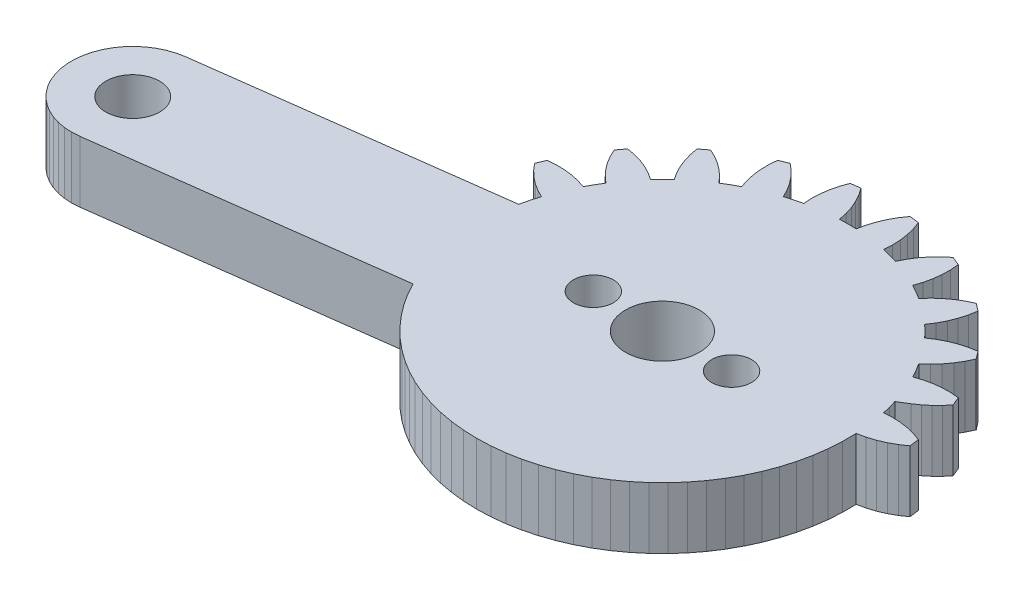
from build123d import *

# Parameters (mm, degrees)
SKETCH1_R           = 1.749998927
SKETCH1_R_2         = 1.299996615
SKETCH1_R_3         = 2.40000119
SKETCH1_R_4         = 1.299996531
BOSS_EXTRUDE1_DEPTH = 4.00000019


with BuildPart() as part:
    # Sketch1 → Boss-Extrude1 (new body)
    with BuildSketch(Plane.XZ):
        Polygon((36.249231547, 26.500970125), (35.366270691, 26.598049328), (34.478571266, 26.630060747), (33.590909094, 26.596819982), (32.708089799, 26.498520747), (31.834870577, 26.335669681), (30.975960195, 26.109160855), (30.135989189, 25.820219889), (29.319489375, 25.470390916), (28.530880809, 25.061579421), (27.774410322, 24.595979601), (27.054149657, 24.076100439), (26.373999193, 23.504760116), (25.737630203, 22.885030136), (25.148460642, 22.220259532), (24.609679356, 21.514030173), (24.124199525, 20.770160481), (23.694630712, 19.992660731), (4.522103816, 22.516779602), (4.020943772, 22.550940514), (3.519453108, 22.522019222), (3.025538987, 22.430479527), (2.54699192, 22.277759388), (2.091363072, 22.066259757), (1.665833988, 21.799329668), (1.277114963, 21.481169388), (0.931337476, 21.11678943), (0.633955002, 20.711960271), (0.389657886, 20.273039117), (0.202298193, 19.806969911), (0.074829914, 19.321080297), (0.009261072, 18.823059276), (0.006631017, 18.320739269), (0.06698072, 17.822049558), (0.189352795, 17.334859818), (0.371821196, 16.866849735), (0.611510186, 16.42539911), (0.90463832, 16.017470509), (1.246578991, 15.649499372), (1.631945022, 15.327280387), (2.05465802, 15.055909753), (2.508047968, 14.839650132), (2.984967083, 14.681920409), (3.477894003, 14.585220255), (22.650420666, 12.061100453), (22.789679468, 11.469890364), (22.958470508, 10.886400007), (22.47623913, 10.642839596), (22.020770237, 10.352309793), (21.596610546, 10.017720051), (21.207999438, 9.642422199), (20.858839154, 9.230175056), (21.09769918, 8.653513156), (21.636100486, 8.608905599), (22.176260129, 8.618320338), (22.712780163, 8.681657724), (23.240279406, 8.798288181), (23.753490299, 8.967043832), (24.014299735, 8.490939625), (24.296209216, 8.027019911), (23.893460631, 7.666944992), (23.528700694, 7.268427871), (23.205589503, 6.835460197), (22.927360609, 6.372373085), (22.696789354, 5.883802194), (23.076770827, 5.388610996), (23.60836044, 5.484871101), (24.127680808, 5.633769091), (24.629529566, 5.833810195), (25.108870119, 6.082994863), (25.560909882, 6.378828082), (25.936059654, 5.986448843), (26.328440756, 5.611301865), (26.032609865, 5.159256049), (25.783419609, 4.679913167), (25.583380833, 4.178069998), (25.434479117, 3.65874893), (25.338219479, 3.127150936), (25.83340928, 2.747178078), (26.321990415, 2.977746073), (26.785070077, 3.255978925), (27.218040079, 3.579091048), (27.616560459, 3.943847958), (27.976630256, 4.346599802), (28.44054997, 4.064687062), (28.916660696, 3.803876927), (28.747899458, 3.290666966), (28.631269932, 2.763161901), (28.567930683, 2.226644894), (28.5585206, 1.68648304), (28.603129089, 1.148083946), (29.179789126, 0.909223221), (29.592040926, 1.25838595), (29.967330396, 1.646994962), (30.301919207, 2.071157098), (30.592450872, 2.526629949), (30.836019665, 3.008852014), (31.35709092, 2.856614999), (31.884480268, 2.727918094), (31.854301691, 2.188517945), (31.878169626, 1.64880103), (31.955849379, 1.114172046), (32.086569816, 0.589979813), (32.269001007, 0.081471168), (32.887838781, 0), (33.195670694, 0.443963305), (33.457588404, 0.916464312), (33.67099911, 1.412771991), (33.833738416, 1.927918987), (33.944208175, 2.456750022), (34.486930817, 2.444565063), (35.029649734, 2.456750022), (35.140108317, 1.927918987), (35.3028588, 1.412771991), (35.516258329, 0.916464312), (35.778190941, 0.443963305), (36.086019129, 0), (36.704860628, 0.081471168), (36.887291819, 0.589979813), (37.01800853, 1.114172046), (37.095680833, 1.64880103), (37.119559944, 2.188517945), (37.089381367, 2.727918094), (37.616759539, 2.856614999), (38.137838244, 3.008852014), (38.381401449, 2.526629949), (38.671940565, 2.071157098), (39.006520063, 1.646994962), (39.381820709, 1.25838595), (39.794068784, 0.909223221), (40.370728821, 1.148083946), (40.415339172, 1.68648304), (40.405929089, 2.226644894), (40.342580527, 2.763161901), (40.225949138, 3.290666966), (40.057200938, 3.803876927), (40.533300489, 4.064687062), (40.997218341, 4.346599802), (41.357301176, 3.943847958), (41.75581038, 3.579091048), (42.18877852, 3.255978925), (42.651869357, 2.977746073), (43.140441179, 2.747178078), (43.635629117, 3.127150936), (43.539371341, 3.65874893), (43.390478939, 4.178069998), (43.19043085, 4.679913167), (42.941249907, 5.159256049), (42.645409703, 5.611301865), (43.037798256, 5.986448843), (43.412938714, 6.378828082), (43.864991516, 6.082994863), (44.344328344, 5.833810195), (44.846169651, 5.633769091), (45.365490019, 5.484871101), (45.897088945, 5.388610996), (46.277068555, 5.883802194), (46.046491712, 6.372373085), (45.768260956, 6.835460197), (45.445151627, 7.268427871), (45.080389827, 7.666944992), (44.677648693, 8.027019911), (44.959560037, 8.490939625), (45.220371336, 8.967043832), (45.733571053, 8.798288181), (46.261079609, 8.681657724), (46.797599643, 8.618320338), (47.337759286, 8.608905599), (47.876160592, 8.653513156), (48.115018755, 9.230175056), (47.80093953, 9.60460864), (47.454301268, 9.949113242), (47.077931464, 10.260869749), (46.674918383, 10.537319817), (46.031348407, 10.937189683), (46.174488962, 11.433199979), (46.296328306, 11.934859678), (46.835720539, 11.904690415), (47.375440598, 11.928560212), (47.910068184, 12.006239966), (48.434268683, 12.136950158), (48.942770809, 12.319389731), (49.024239182, 12.938220054), (48.580281436, 13.246050104), (48.107780516, 13.507979922), (47.611471266, 13.721389696), (47.096319497, 13.884129934), (46.567488462, 13.994590379), (46.574741602, 14.882840216), (46.516768634, 15.769220889), (46.393878758, 16.648959368), (46.206749976, 17.517309636), (45.956380665, 18.369570374), (45.644130558, 19.201159477), (45.271679759, 20.007580519), (44.84102875, 20.784480497), (44.354520738, 21.527679637), (43.814770877, 22.233160213), (43.224681169, 22.897120565), (42.587451637, 23.515969515), (41.906509548, 24.086369202), (41.185539216, 24.605249986), (40.428418666, 25.069799274), (39.639238268, 25.477530435), (38.82227093, 25.826219469), (37.981901318, 26.114009321), (37.122670561, 26.339329779), align=None)
        with Locations((4.001719752, 18.55742414)):
            Circle(SKETCH1_R, mode=Mode.SUBTRACT)
        with Locations((38.991415321, 14.535226811)):
            Circle(SKETCH1_R_2, mode=Mode.SUBTRACT)
        with Locations((34.486927148, 14.537310838)):
            Circle(SKETCH1_R_3, mode=Mode.SUBTRACT)
        with Locations((29.986932547, 14.537316418)):
            Circle(SKETCH1_R_4, mode=Mode.SUBTRACT)
    extrude(amount=-BOSS_EXTRUDE1_DEPTH)


solid = part.part
